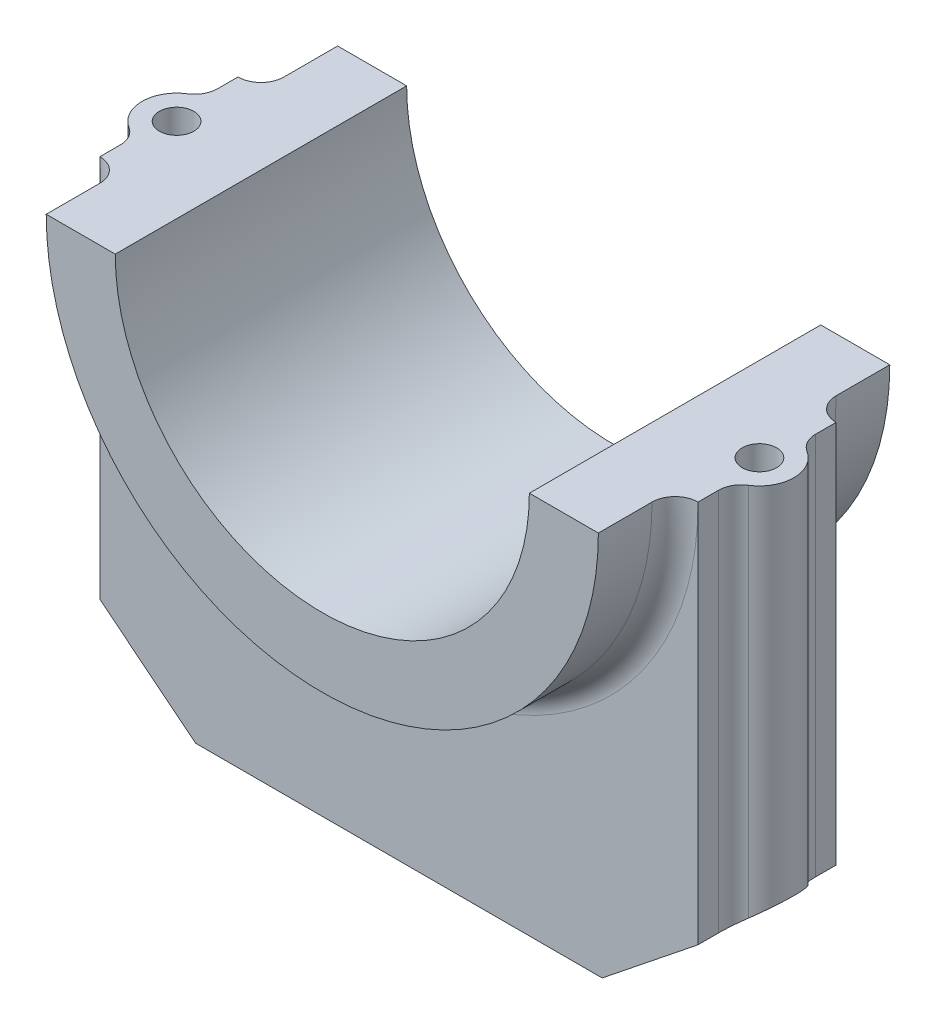
from build123d import *

# Parameters (mm, degrees)
BOSS_EXTRUDE1_DEPTH = 19
BOSS_EXTRUDE2_DEPTH = 9
FILLET5_R           = 3
CUT_EXTRUDE2_REACH  = 83.322
SKETCH2_R           = 2.25
FILLET6_R           = 3


with BuildPart() as part:
    # Sketch1 → Boss-Extrude1 (new, symmetric)
    with BuildSketch(Plane.XY):
        with BuildLine():
            ThreePointArc((27, 0), (0, -27), (-27, 0))
            Line((-27, 0), (-36, 0))
            ThreePointArc((-36, 0), (0, -36), (36, 0))
            Line((36, 0), (27, 0))
        make_face()
    extrude(amount=BOSS_EXTRUDE1_DEPTH, both=True)

    # Sketch1_3 → Boss-Extrude2 (add, symmetric)
    with BuildSketch(Plane.XY):
        with BuildLine():
            ThreePointArc((36, 0), (0, -36), (-36, 0))
            Line((-36, 0), (-51.5, 0))
            Line((-51.5, 0), (-51.5, -40))
            Line((-51.5, -40), (-26.5, -60))
            Line((-26.5, -60), (26.5, -60))
            Line((26.5, -60), (51.5, -40))
            Line((51.5, -40), (51.5, 0))
            Line((51.5, 0), (36, 0))
        make_face()
    extrude(amount=BOSS_EXTRUDE2_DEPTH, both=True)

    # Fillet5
    fillet5_edges = [part.edges().sort_by_distance(p)[0] for p in [
        (0, -36, -9),
        (0, -36, 9),
    ]]
    fillet(fillet5_edges, radius=FILLET5_R)

    # Sketch2 → Cut-Extrude2 (cut, up to next)
    with BuildSketch(Plane(origin=(0, 0, 0), x_dir=(1, 0, 0), z_dir=(0, 1, 0)), mode=Mode.PRIVATE) as cut_extrude2_sk1:
        with BuildLine():
            Line((51.5, 9), (39, 9))
            Line((39, 9), (39, 4.387482194))
            ThreePointArc((39, 4.387482194), (42.5, 0), (39, -4.387482194))
            Line((39, -4.387482194), (39, -9))
            Line((39, -9), (51.5, -9))
            Line((51.5, -9), (51.5, 9))
        make_face()
    cut_extrude2_tool1 = extrude(cut_extrude2_sk1.sketch, amount=-CUT_EXTRUDE2_REACH, mode=Mode.PRIVATE) & part.part
    # Sketch2 → Cut-Extrude2 (cut, up to next)
    with BuildSketch(Plane(origin=(0, 0, 0), x_dir=(1, 0, 0), z_dir=(0, 1, 0)), mode=Mode.PRIVATE) as cut_extrude2_sk2:
        with Locations((38, 0)):
            Circle(SKETCH2_R)
    cut_extrude2_tool2 = extrude(cut_extrude2_sk2.sketch, amount=-CUT_EXTRUDE2_REACH, mode=Mode.PRIVATE) & part.part
    # Sketch2 → Cut-Extrude2 (cut, up to next)
    with BuildSketch(Plane(origin=(0, 0, 0), x_dir=(1, 0, 0), z_dir=(0, 1, 0)), mode=Mode.PRIVATE) as cut_extrude2_sk3:
        with BuildLine():
            Line((-39, 4.387482194), (-39, 9))
            Line((-39, 9), (-51.5, 9))
            Line((-51.5, 9), (-51.5, -9))
            Line((-51.5, -9), (-39, -9))
            Line((-39, -9), (-39, -4.387482194))
            ThreePointArc((-39, -4.387482194), (-42.5, 0), (-39, 4.387482194))
        make_face()
    cut_extrude2_tool3 = extrude(cut_extrude2_sk3.sketch, amount=-CUT_EXTRUDE2_REACH, mode=Mode.PRIVATE) & part.part
    # Sketch2 → Cut-Extrude2 (cut, up to next)
    with BuildSketch(Plane(origin=(0, 0, 0), x_dir=(1, 0, 0), z_dir=(0, 1, 0)), mode=Mode.PRIVATE) as cut_extrude2_sk4:
        with Locations((-38, 0)):
            Circle(SKETCH2_R)
    cut_extrude2_tool4 = extrude(cut_extrude2_sk4.sketch, amount=-CUT_EXTRUDE2_REACH, mode=Mode.PRIVATE) & part.part
    add(cut_extrude2_tool1.solids().sort_by_distance((45.792249, 0, 0))[0], mode=Mode.SUBTRACT)
    add(cut_extrude2_tool2.solids().sort_by_distance((38, 0, 0))[0], mode=Mode.SUBTRACT)
    add(cut_extrude2_tool3.solids().sort_by_distance((-45.792249, 0, 0))[0], mode=Mode.SUBTRACT)
    add(cut_extrude2_tool4.solids().sort_by_distance((-38, 0, 0))[0], mode=Mode.SUBTRACT)

    # Fillet6
    fillet6_edges = [part.edges().sort_by_distance(p)[0] for p in [
        (-39, -25, -4.387482194),
        (-39, -25, 4.387482194),
        (39, -25, 4.387482194),
        (39, -25, -4.387482194),
    ]]
    fillet(fillet6_edges, radius=FILLET6_R)


solid = part.part
